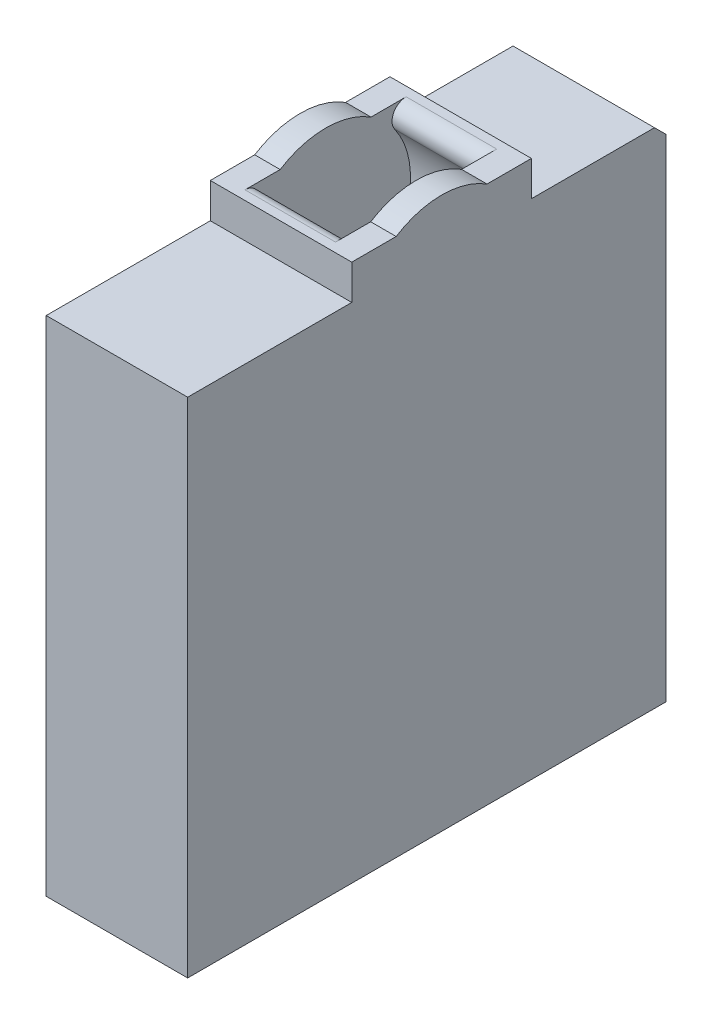
from build123d import *

# Parameters (mm, degrees)
BOSS_EXTRUDE1_DEPTH = 25
BOSS_EXTRUDE2_DEPTH = 25
CUT_EXTRUDE1_START  = -4.5
SKETCH3_R           = 15
CUT_EXTRUDE1_DEPTH  = 16
CHAMFER1_SIZE       = 2
FILLET2_R           = 2.5


with BuildPart() as part:
    # Sketch1 → Boss-Extrude1 (new body)
    with BuildSketch(Plane(origin=(0, 0, 0), x_dir=(0, 0, -1), z_dir=(1, 0, 0))):
        Polygon((-44.875, -95.07), (-44.875, -6.17), (-15.875, -6.17), (-15.875, 0), (15.875, 0), (15.875, -6.17), (39.625, -6.17), (39.625, -95.07), align=None)
    extrude(amount=BOSS_EXTRUDE1_DEPTH)

    # Sketch2 → Boss-Extrude2 (add)
    with BuildSketch(Plane(origin=(25, 0, 0), x_dir=(0, 0, -1), z_dir=(1, 0, 0))):
        with BuildLine():
            Line((-8.029389765, 0), (8.029389765, 0))
            ThreePointArc((8.029389765, 0), (0, 2.33), (-8.029389765, 0))
        make_face()
    extrude(amount=-BOSS_EXTRUDE2_DEPTH)

    # Sketch3 → Cut-Extrude1 (cut)
    with BuildSketch(Plane(origin=(25, 0, 0), x_dir=(0, 0, -1), z_dir=(1, 0, 0)).offset(CUT_EXTRUDE1_START)):
        with Locations((0, -12.67)):
            Circle(SKETCH3_R)
    extrude(amount=-CUT_EXTRUDE1_DEPTH, mode=Mode.SUBTRACT)

    # Chamfer1
    chamfer1_edges = [part.edges().sort_by_distance(p)[0] for p in [
        (12.5, -6.17, -39.625),
    ]]
    chamfer(chamfer1_edges, length=CHAMFER1_SIZE)

    # Fillet2
    fillet2_edges = [part.edges().sort_by_distance(p)[0] for p in [
        (12.5, 0, -8.029389765),
        (12.5, 0, 8.029389765),
    ]]
    fillet(fillet2_edges, radius=FILLET2_R)


solid = part.part
